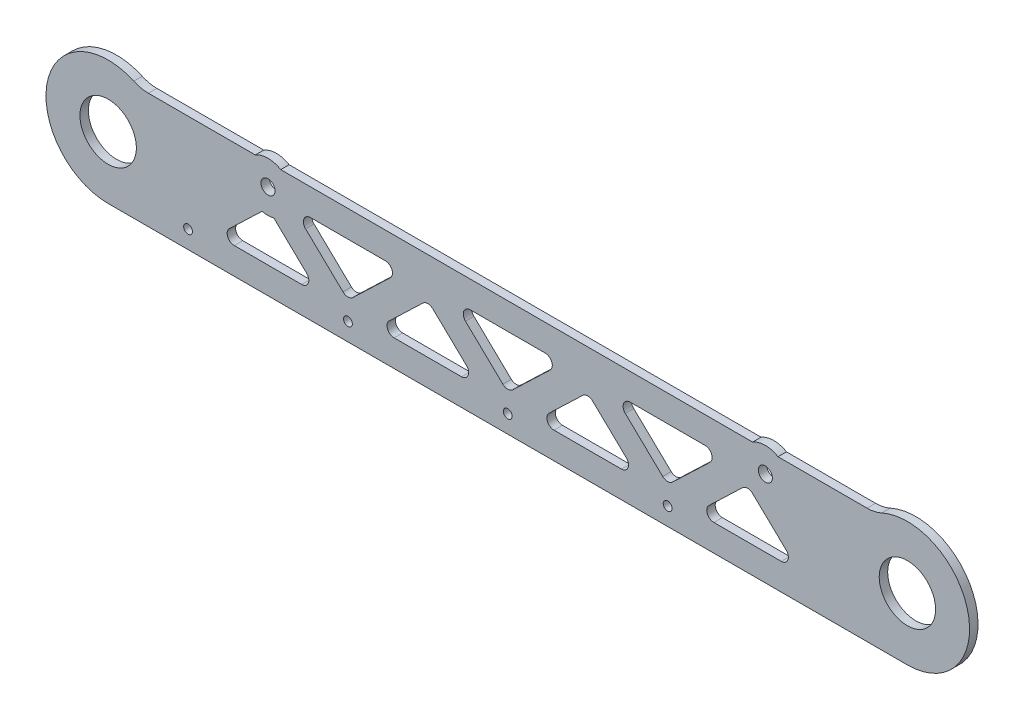
from build123d import *

# Parameters (mm, degrees)
BOSS_EXTRUDE1_DEPTH     = 4.7625
SKETCH2_R               = 3.96875
SKETCH2_R_2             = 15.875
CUT_EXTRUDE1_DEPTH      = 1
CUT_EXTRUDE1_DEPTH_BACK = 5.7625
F_10_CLEARANCE_HOLE2_D  = 4.9784
CUT_EXTRUDE3_DEPTH      = 5.7625
CUT_EXTRUDE4_DEPTH      = 5.7625
FILLET1_R               = 4
LPATTERN1_COUNT         = 4
LPATTERN1_PITCH         = 90
FILLET1_OF_LPATTERN1_R  = 4
CUT_EXTRUDE5_DEPTH      = 5.7625
FILLET2_R               = 4
LPATTERN2_COUNT         = 3
LPATTERN2_PITCH         = 90
FILLET2_OF_LPATTERN2_R  = 4
SKETCH13_R              = 13.96875
SKETCH13_R_2            = 3.96875
BOSS_EXTRUDE2_DEPTH     = 4.7625
FILLET3_R               = 20


with BuildPart() as part:
    # Sketch1 → Boss-Extrude1 (new body)
    with BuildSketch(Plane.XY):
        with BuildLine():
            Line((-225, 35), (225, 35))
            ThreePointArc((225, 35), (260, 0), (225, -35))
            Line((225, -35), (-225, -35))
            ThreePointArc((-225, -35), (-260, 0), (-225, 35))
        make_face()
    extrude(amount=BOSS_EXTRUDE1_DEPTH)

    # Sketch2 → Cut-Extrude1 (cut, two sides)
    with BuildSketch(Plane(origin=(0, 0, 0), x_dir=(-1, 0, 0), z_dir=(0, 0, -1))) as cut_extrude1_sk:
        with Locations((-145, 18.1)):
            Circle(SKETCH2_R)
        with Locations((135, 18.1)):
            Circle(SKETCH2_R)
        with Locations((-225, 0)):
            Circle(SKETCH2_R_2)
        with Locations((225, 0)):
            Circle(SKETCH2_R_2)
    extrude(amount=CUT_EXTRUDE1_DEPTH, mode=Mode.SUBTRACT)
    extrude(cut_extrude1_sk.sketch, amount=-CUT_EXTRUDE1_DEPTH_BACK, mode=Mode.SUBTRACT)

    # #10 Clearance Hole2 (through all)
    with Locations(Plane.XY.offset(4.7625)):
        with Locations((-180, -25), (-90, -25), (0, -25), (90, -25)):
            Hole(F_10_CLEARANCE_HOLE2_D / 2)

    # Sketch16 → Cut-Extrude3 (cut, through all)
    with BuildSketch(Plane.XY.offset(4.7625)):
        with BuildLine():
            Line((-207.139708849, 30.1), (207.139708849, 30.1))
            ThreePointArc((207.139708849, 30.1), (215.739870411, 33.752777663), (225, 35))
            Line((225, 35), (-225, 35))
            ThreePointArc((-225, 35), (-215.739870411, 33.752777663), (-207.139708849, 30.1))
        make_face()
    extrude(amount=-CUT_EXTRUDE3_DEPTH, mode=Mode.SUBTRACT)

    # Sketch17 → Cut-Extrude4 (cut, through all)
    with BuildSketch(Plane.XY.offset(4.7625)):
        Polygon((-106.063328248, -20), (-135, 7.714901167), (-163.936671752, -20), align=None)
    cut_extrude4 = extrude(amount=-CUT_EXTRUDE4_DEPTH, mode=Mode.SUBTRACT)

    # Fillet1
    fillet1_edges = [part.edges().sort_by_distance(p)[0] for p in [
        (-163.936671752, -20, 2.38125),
        (-135, 7.714901167, 2.38125),
        (-106.063328248, -20, 2.38125),
    ]]
    fillet(fillet1_edges, radius=FILLET1_R)

    # LPattern1: Cut-Extrude4 ×4
    with Locations(*[(i * LPATTERN1_PITCH, 0, 0) for i in range(1, LPATTERN1_COUNT)]):
        add(cut_extrude4, mode=Mode.SUBTRACT)

    # Fillet1 of LPattern1
    fillet1_of_lpattern1_edges = [part.edges().sort_by_distance(p)[0] for p in [
        (-73.936671752, -20, 2.38125),
        (-45, 7.714901167, 2.38125),
        (-16.063328248, -20, 2.38125),
        (16.063328248, -20, 2.38125),
        (45, 7.714901167, 2.38125),
        (73.936671752, -20, 2.38125),
        (106.063328248, -20, 2.38125),
        (135, 7.714901167, 2.38125),
        (163.936671752, -20, 2.38125),
    ]]
    fillet(fillet1_of_lpattern1_edges, radius=FILLET1_OF_LPATTERN1_R)

    # Sketch18 → Cut-Extrude5 (cut, through all)
    with BuildSketch(Plane.XY.offset(4.7625)):
        Polygon((-90, -14.614901167), (-58.975161195, 15.1), (-121.024838805, 15.1), align=None)
    cut_extrude5 = extrude(amount=-CUT_EXTRUDE5_DEPTH, mode=Mode.SUBTRACT)

    # Fillet2
    fillet2_edges = [part.edges().sort_by_distance(p)[0] for p in [
        (-121.024838805, 15.1, 2.38125),
        (-58.975161195, 15.1, 2.38125),
        (-90, -14.614901167, 2.38125),
    ]]
    fillet(fillet2_edges, radius=FILLET2_R)

    # LPattern2: Cut-Extrude5 ×3
    with Locations(*[(i * LPATTERN2_PITCH, 0, 0) for i in range(1, LPATTERN2_COUNT)]):
        add(cut_extrude5, mode=Mode.SUBTRACT)

    # Fillet2 of LPattern2
    fillet2_of_lpattern2_edges = [part.edges().sort_by_distance(p)[0] for p in [
        (-31.024838805, 15.1, 2.38125),
        (31.024838805, 15.1, 2.38125),
        (0, -14.614901167, 2.38125),
        (58.975161195, 15.1, 2.38125),
        (121.024838805, 15.1, 2.38125),
        (90, -14.614901167, 2.38125),
    ]]
    fillet(fillet2_of_lpattern2_edges, radius=FILLET2_OF_LPATTERN2_R)

    # Sketch13 → Boss-Extrude2 (add)
    with BuildSketch(Plane.XY.offset(4.7625)):
        with Locations((-135, 18.1)):
            Circle(SKETCH13_R)
        with Locations((-135, 18.1)):
            Circle(SKETCH13_R_2, mode=Mode.SUBTRACT)
        with Locations((145, 18.1)):
            Circle(SKETCH13_R)
        with Locations((145, 18.1)):
            Circle(SKETCH13_R_2, mode=Mode.SUBTRACT)
    extrude(amount=-BOSS_EXTRUDE2_DEPTH)

    # Fillet3
    fillet3_edges = [part.edges().sort_by_distance(p)[0] for p in [
        (-207.139708849, 30.1, 2.38125),
        (207.139708849, 30.1, 2.38125),
    ]]
    fillet(fillet3_edges, radius=FILLET3_R)


solid = part.part
